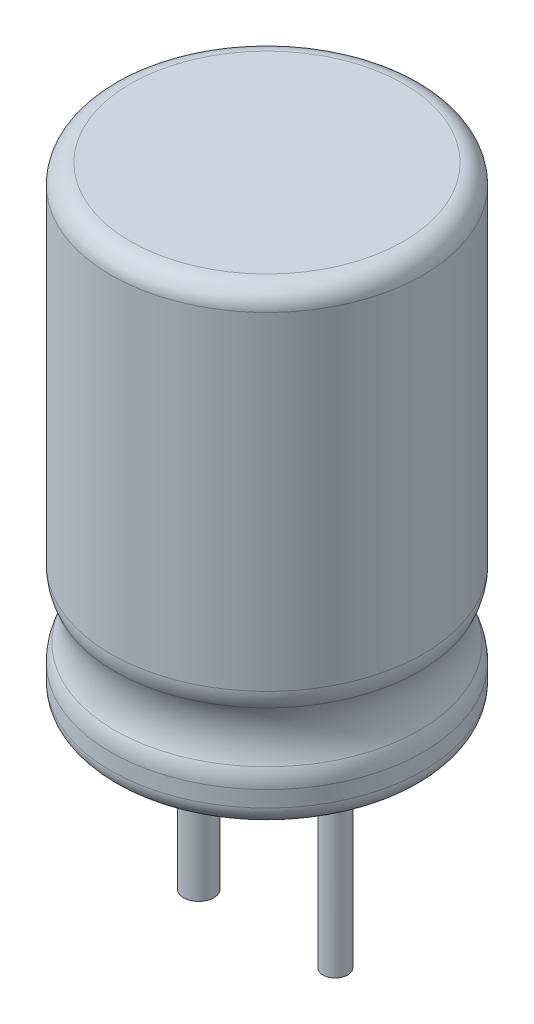
from build123d import *

# Parameters (mm, degrees)
SKETCH1_R           = 4
BOSS_EXTRUDE1_DEPTH = 12
SKETCH2_R           = 0.317566637
SKETCH2_R_2         = 0.388464661
BOSS_EXTRUDE2_DEPTH = 5
SKETCH3_R           = 1.5
FILLET1_R           = 1
FILLET2_R           = 0.5
FILLET3_R           = 0.5


with BuildPart() as part:
    # Sketch1 → Boss-Extrude1 (new body)
    with BuildSketch(Plane(origin=(0, 0, 0), x_dir=(1, 0, 0), z_dir=(0, 1, 0))):
        Circle(SKETCH1_R)
    extrude(amount=BOSS_EXTRUDE1_DEPTH)

    # Sketch2 → Boss-Extrude2 (add)
    with BuildSketch(Plane.XZ):
        with Locations((1.75, 0)):
            Circle(SKETCH2_R)
        with Locations((-1.75, 0)):
            Circle(SKETCH2_R_2)
    extrude(amount=BOSS_EXTRUDE2_DEPTH)

    # Sketch3 → Cut-Revolve1 (revolve, cut)
    with BuildSketch(Plane(origin=(0, 0, 0), x_dir=(0, 0, -1), z_dir=(1, 0, 0))):
        with Locations((5.25, 2)):
            Circle(SKETCH3_R)
    revolve(axis=Axis((0, 22.78154861, 0), (0, -1, 0)), mode=Mode.SUBTRACT)

    # Fillet1
    fillet1_edges = [part.edges().sort_by_distance(p)[0] for p in [
        (-2.828427125, 2.829156198, 2.828427125),
        (-2.828427125, 1.170843802, 2.828427125),
    ]]
    fillet(fillet1_edges, radius=FILLET1_R)

    # Fillet2
    fillet2_edges = [part.edges().sort_by_distance(p)[0] for p in [
        (-4, 12, 0),
    ]]
    fillet(fillet2_edges, radius=FILLET2_R)

    # Fillet3
    fillet3_edges = [part.edges().sort_by_distance(p)[0] for p in [
        (-4, 0, 0),
    ]]
    fillet(fillet3_edges, radius=FILLET3_R)


solid = part.part
